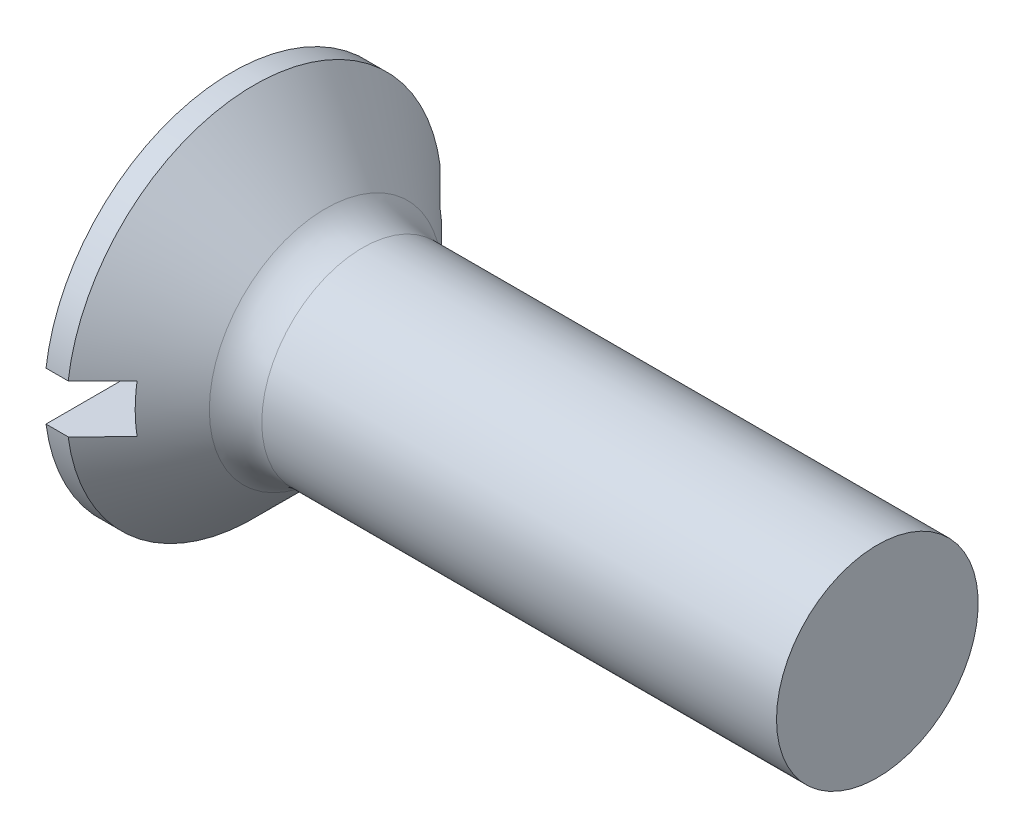
from build123d import *

# Parameters (mm, degrees)
FILLET1_R  = 1.3
SKETCH2_W  = 9.3
SKETCH2_H  = 1.2
SLOT_DEPTH = 1.4


with BuildPart() as part:
    # BodySke → Base-Revolve (revolve)
    with BuildSketch(Plane.XY):
        Polygon((0, 0), (0, 4.65), (0.55, 4.65), (2.7, 2.5), (16, 2.5), (16, 0), align=None)
    revolve(axis=Axis((-6.35, 0, 0), (1, 0, 0)))

    # Fillet1
    fillet1_edges = [part.edges().sort_by_distance(p)[0] for p in [
        (2.7, -2.5, 0),
    ]]
    fillet(fillet1_edges, radius=FILLET1_R)

    # Sketch2 → Slot (cut)
    with BuildSketch(Plane.ZY):
        Rectangle(SKETCH2_W, SKETCH2_H)
    extrude(amount=-SLOT_DEPTH, mode=Mode.SUBTRACT)


solid = part.part
